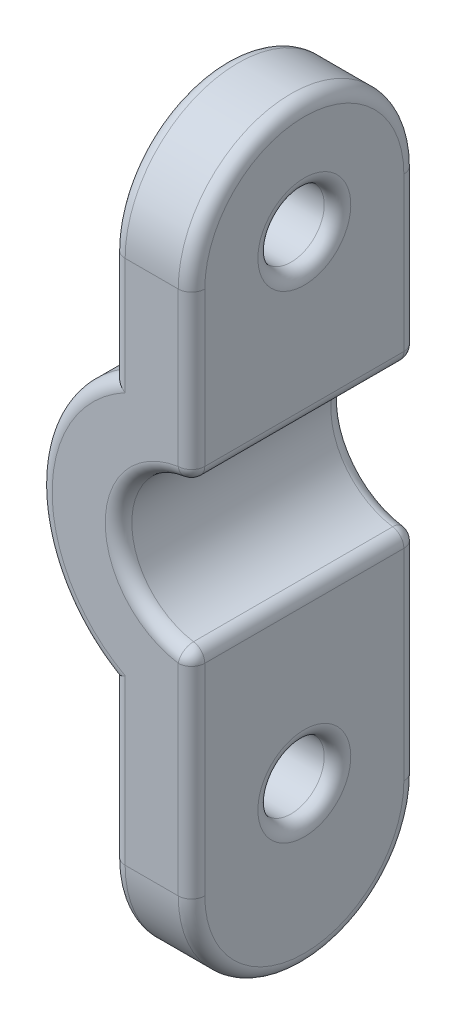
from build123d import *

# Parameters (mm, degrees)
BOSS_EXTRUDE1_DEPTH = 12.5
SKETCH2_W           = 12.5
SKETCH2_H           = 30.5
SKETCH2_R           = 1.25
CUT_EXTRUDE1_DEPTH  = 9.5
FILLET1_R           = 0.5


with BuildPart() as part:
    # Sketch1 → Boss-Extrude1 (new body)
    with BuildSketch(Plane.XY):
        with BuildLine():
            ThreePointArc((-2.75, 3.65), (-5.5, 0.9), (-2.75, -1.85))
            Line((-2.75, -1.85), (-2.75, -14.35))
            Line((-2.75, -14.35), (-5.75, -14.35))
            Line((-5.75, -14.35), (-5.75, -4.005354218))
            ThreePointArc((-5.75, -4.005354218), (-8.5, 0.9), (-5.75, 5.805354218))
            Line((-5.75, 5.805354218), (-5.75, 16.15))
            Line((-5.75, 16.15), (-2.75, 16.15))
            Line((-2.75, 16.15), (-2.75, 3.65))
        make_face()
    extrude(amount=BOSS_EXTRUDE1_DEPTH)

    # Sketch2 → Cut-Extrude1 (cut, through all)
    with BuildSketch(Plane(origin=(0, 0, 0), x_dir=(0, 0, -1), z_dir=(1, 0, 0))):
        with Locations((-6.25, 0.9)):
            Rectangle(SKETCH2_W, SKETCH2_H)
        with BuildLine():
            ThreePointArc((-10.5, -9.9), (-6.25, -14.15), (-2, -9.9))
            Line((-2, -9.9), (-2, 9.9))
            ThreePointArc((-2, 9.9), (-6.25, 14.15), (-10.5, 9.9))
            Line((-10.5, 9.9), (-10.5, -9.9))
        make_face(mode=Mode.SUBTRACT)
        with Locations((-6.25, 9.9)):
            Circle(SKETCH2_R)
        with Locations((-6.25, -8.1)):
            Circle(SKETCH2_R)
    extrude(amount=-CUT_EXTRUDE1_DEPTH, mode=Mode.SUBTRACT)

    # Fillet1
    fillet1_edges = [part.edges().sort_by_distance(p)[0] for p in [
        (-2.75, -1.85, 6.25),
        (-2.75, -5.875, 10.5),
        (-2.75, -14.15, 6.25),
        (-2.75, -5.875, 2),
        (-5.75, 14.15, 6.25),
        (-2.75, 3.65, 6.25),
        (-5.75, -8.1, 7.5),
        (-2.75, -8.1, 7.5),
        (-2.75, 9.9, 7.5),
        (-5.75, 9.9, 7.5),
        (-2.75, 14.15, 6.25),
        (-5.75, -14.15, 6.25),
        (-5.75, 7.852677109, 2),
        (-8.5, 0.9, 2),
        (-2.75, 6.775, 2),
        (-5.5, 0.9, 2),
        (-2.75, 6.775, 10.5),
        (-5.5, 0.9, 10.5),
        (-5.75, -6.952677109, 10.5),
        (-5.75, 7.852677109, 10.5),
        (-8.5, 0.9, 10.5),
        (-5.75, -6.952677109, 2),
    ]]
    fillet(fillet1_edges, radius=FILLET1_R)


solid = part.part
